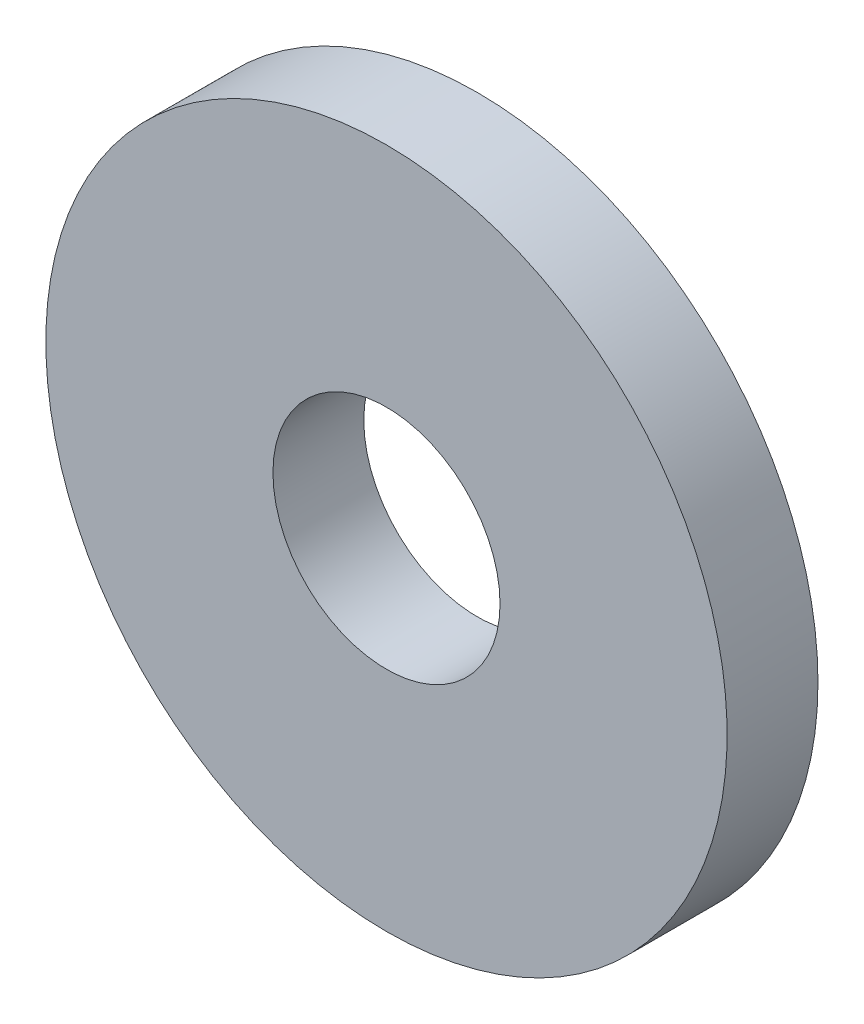
from build123d import *

# Parameters (mm, degrees)
SKETCH2_R           = 9.525
SKETCH2_R_2         = 3.175
BOSS_EXTRUDE1_DEPTH = 2.54
SKETCH3_R           = 3.175
CUT_EXTRUDE1_DEPTH  = 19.05


with BuildPart() as part:
    # Sketch2 → Boss-Extrude1 (new body)
    with BuildSketch(Plane.XY):
        with Locations((-86.337471769, -75.866410674)):
            Circle(SKETCH2_R)
        with Locations((-86.337471769, -75.866410674)):
            Circle(SKETCH2_R_2, mode=Mode.SUBTRACT)
        with Locations((-86.337471769, -75.866410674)):
            Circle(SKETCH2_R_2)
    extrude(amount=BOSS_EXTRUDE1_DEPTH)

    # Sketch3 → Cut-Extrude1 (cut)
    with BuildSketch(Plane.XY.offset(2.54)):
        with Locations((-86.337471769, -75.866410674)):
            Circle(SKETCH3_R)
    extrude(amount=-CUT_EXTRUDE1_DEPTH, mode=Mode.SUBTRACT)


solid = part.part
